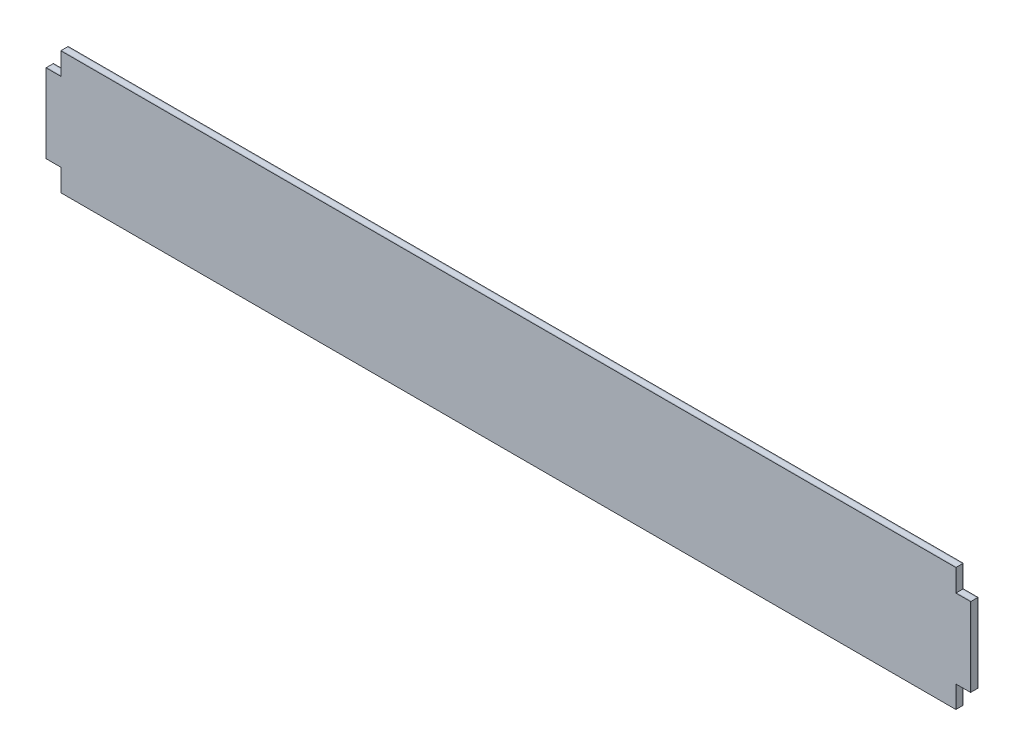
from build123d import *

# Parameters (mm, degrees)
BOSS_EXTRUDE1_DEPTH = 0.25
BOSS_EXTRUDE2_DEPTH = 2.5
BOSS_EXTRUDE3_DEPTH = 0.25


with BuildPart() as part:
    # Sketch1 → Boss-Extrude1 (new body)
    with BuildSketch(Plane.XY):
        Polygon((-182, 25), (-182, 16), (-188, 16), (-188, -16), (-182, -16), (-182, -25), (182, -25), (182, -16), (188, -16), (188, 16), (182, 16), (182, 25), align=None)
    extrude(amount=BOSS_EXTRUDE1_DEPTH)


with BuildPart() as body_2:
    # Sketch2 → Boss-Extrude2 (new body)
    with BuildSketch(Plane(origin=(0, 0, 0), x_dir=(-1, 0, 0), z_dir=(0, 0, -1))):
        Polygon((182, 16), (182, 25), (-182, 25), (-182, 16), (-188, 16), (-188, -16), (-182, -16), (-182, -25), (182, -25), (182, -16), (188, -16), (188, 16), align=None)
    extrude(amount=BOSS_EXTRUDE2_DEPTH)


with BuildPart() as body_3:
    # Sketch3 → Boss-Extrude3 (new body)
    with BuildSketch(Plane(origin=(0, 0, -2.5), x_dir=(-1, 0, 0), z_dir=(0, 0, -1))):
        Polygon((182, 16), (182, 25), (-182, 25), (-182, 16), (-188, 16), (-188, -16), (-182, -16), (-182, -25), (182, -25), (182, -16), (188, -16), (188, 16), align=None)
    extrude(amount=BOSS_EXTRUDE3_DEPTH)


solid = Compound([part.part, body_2.part, body_3.part])
